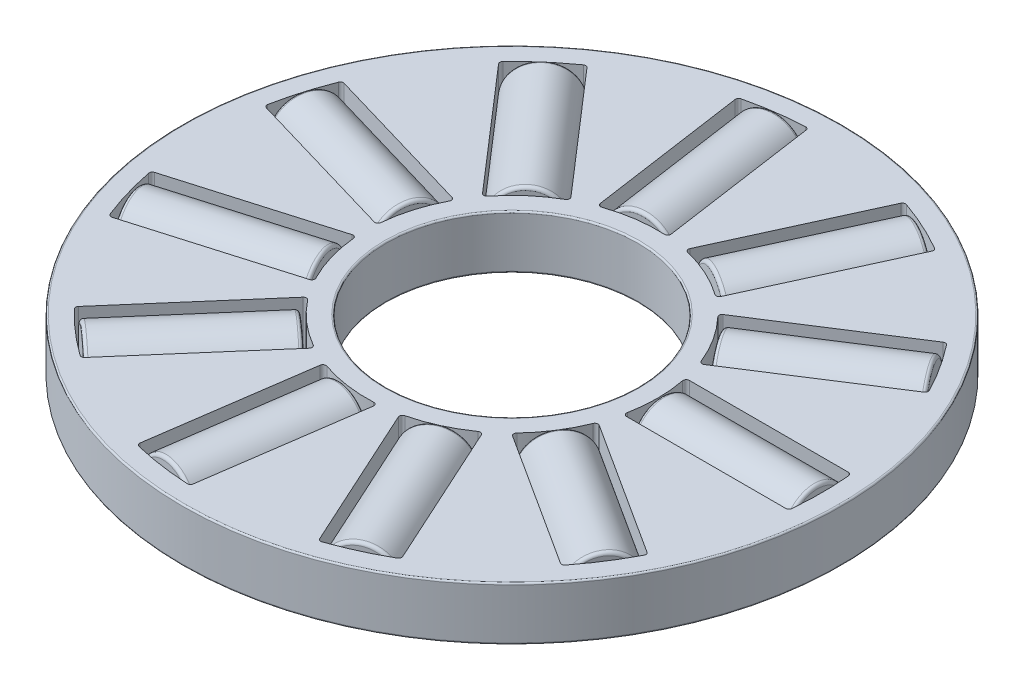
from build123d import *

# Parameters (mm, degrees)
SKETCH3_W                = 6.4875
SKETCH3_H                = 1.7
FILLET1_R                = 0.05
CUT_EXTRUDE1_DEPTH       = 1.85
FILLET5_R                = 0.1
CIRPATTERN1_COUNT        = 11
FILLET5_OF_CIRPATTERN1_R = 0.1
SKETCH5_W                = 4.96375
SKETCH5_H                = 0.998287418
FILLET6_R                = 0.1
CIRPATTERN2_COUNT        = 11


with BuildPart() as part:
    # Sketch3 → Revolve1 (revolve)
    with BuildSketch(Plane(origin=(0, 0, 0), x_dir=(0, 0, -1), z_dir=(1, 0, 0))):
        with Locations((7.25625, 0)):
            Rectangle(SKETCH3_W, SKETCH3_H)
    revolve(axis=Axis((0, 1, 0), (0, -1, 0)))

    # Fillet1
    fillet1_edges = [part.edges().sort_by_distance(p)[0] for p in [
        (0, 0.85, 4.0125),
        (0, 0.85, 10.5),
        (0, -0.85, 10.5),
        (0, -0.85, 4.0125),
    ]]
    fillet(fillet1_edges, radius=FILLET1_R)

    # Sketch4 → Cut-Extrude1 (cut, symmetric)
    with BuildSketch(Plane(origin=(0, 0, 0), x_dir=(1, 0, 0), z_dir=(0, 1, 0))):
        with BuildLine():
            Line((4.528777813, 0.998287418), (9.811846334, 0.998287418))
            ThreePointArc((9.811846334, 0.998287418), (9.8625, 0), (9.811846334, -0.998287418))
            Line((9.811846334, -0.998287418), (4.528777813, -0.998287418))
            ThreePointArc((4.528777813, -0.998287418), (4.6375, 0), (4.528777813, 0.998287418))
        make_face()
    cut_extrude1 = extrude(amount=CUT_EXTRUDE1_DEPTH, both=True, mode=Mode.SUBTRACT)

    # Fillet5
    fillet5_edges = [part.edges().sort_by_distance(p)[0] for p in [
        (4.528777813, 0, 0.998287418),
        (4.528777813, 0, -0.998287418),
        (9.811846334, 0, -0.998287418),
        (9.811846334, 0, 0.998287418),
    ]]
    fillet(fillet5_edges, radius=FILLET5_R)

    # CirPattern1: Cut-Extrude1 ×11 about axis
    cirpattern1_axis = Axis((0, 0, 0), (0, 1, 0))
    for i in range(1, CIRPATTERN1_COUNT):
        add(cut_extrude1.rotate(cirpattern1_axis, i * 360 / CIRPATTERN1_COUNT), mode=Mode.SUBTRACT)

    # Fillet5 of CirPattern1
    fillet5_of_cirpattern1_edges = [part.edges().sort_by_distance(p)[0] for p in [
        (4.34956526, 0, -1.608629322),
        (3.270135409, 0, -3.288254956),
        (7.714535467, 0, -6.14449744),
        (8.793965318, 0, -4.464871806),
        (2.78939647, 0, -3.704817618),
        (0.973248119, 0, -4.534224779),
        (3.167914097, 0, -9.339872939),
        (4.984062448, 0, -8.510465778),
        (0.343614009, 0, -4.624752497),
        (-1.632638573, 0, -4.340610273),
        (-2.384497615, 0, -9.569904773),
        (-0.408245033, 0, -9.854046998),
        (-2.211263472, 0, -4.076361136),
        (-3.720174054, 0, -2.768882674),
        (-7.179848183, 0, -6.76155946),
        (-5.670937601, 0, -8.069037922),
        (-4.064080424, 0, -2.233753916),
        (-4.626580558, 0, -0.31805439),
        (-9.695647682, 0, -1.806466792),
        (-9.133147549, 0, -3.722166318),
        (-4.626580558, 0, 0.31805439),
        (-4.064080424, 0, 2.233753916),
        (-9.133147549, 0, 3.722166318),
        (-9.695647682, 0, 1.806466792),
        (-3.720174054, 0, 2.768882674),
        (-2.211263472, 0, 4.076361136),
        (-5.670937601, 0, 8.069037922),
        (-7.179848183, 0, 6.76155946),
        (-1.632638573, 0, 4.340610273),
        (0.343614009, 0, 4.624752497),
        (-0.408245033, 0, 9.854046998),
        (-2.384497615, 0, 9.569904773),
        (0.973248119, 0, 4.534224779),
        (2.78939647, 0, 3.704817618),
        (4.984062448, 0, 8.510465778),
        (3.167914097, 0, 9.339872939),
        (3.270135409, 0, 3.288254956),
        (4.34956526, 0, 1.608629322),
        (8.793965318, 0, 4.464871806),
        (7.714535467, 0, 6.14449744),
    ]]
    fillet(fillet5_of_cirpattern1_edges, radius=FILLET5_OF_CIRPATTERN1_R)


with BuildPart() as body_2:
    # Sketch5 → Revolve2 (revolve)
    with BuildSketch(Plane(origin=(0, 0, 0), x_dir=(1, 0, 0), z_dir=(0, 1, 0))):
        with Locations((7.25, 0.499143709)):
            Rectangle(SKETCH5_W, SKETCH5_H)
    revolve(axis=Axis((9.8625, 0, 0), (-1, 0, 0)))

    # Fillet6
    fillet6_edges = [body_2.edges().sort_by_distance(p)[0] for p in [
        (9.731875, 0, 0.998287418),
        (4.768125, 0, 0.998287418),
    ]]
    fillet(fillet6_edges, radius=FILLET6_R)


with BuildPart() as cirpattern2_1:
    # CirPattern2: pattern copy
    add(body_2.part.rotate(Axis((0, 0, 0), (0, 1, 0)), 1 * 360 / CIRPATTERN2_COUNT))


with BuildPart() as cirpattern2_2:
    # CirPattern2: pattern copy
    add(body_2.part.rotate(Axis((0, 0, 0), (0, 1, 0)), 2 * 360 / CIRPATTERN2_COUNT))


with BuildPart() as cirpattern2_3:
    # CirPattern2: pattern copy
    add(body_2.part.rotate(Axis((0, 0, 0), (0, 1, 0)), 3 * 360 / CIRPATTERN2_COUNT))


with BuildPart() as cirpattern2_4:
    # CirPattern2: pattern copy
    add(body_2.part.rotate(Axis((0, 0, 0), (0, 1, 0)), 4 * 360 / CIRPATTERN2_COUNT))


with BuildPart() as cirpattern2_5:
    # CirPattern2: pattern copy
    add(body_2.part.rotate(Axis((0, 0, 0), (0, 1, 0)), 5 * 360 / CIRPATTERN2_COUNT))


with BuildPart() as cirpattern2_6:
    # CirPattern2: pattern copy
    add(body_2.part.rotate(Axis((0, 0, 0), (0, 1, 0)), 6 * 360 / CIRPATTERN2_COUNT))


with BuildPart() as cirpattern2_7:
    # CirPattern2: pattern copy
    add(body_2.part.rotate(Axis((0, 0, 0), (0, 1, 0)), 7 * 360 / CIRPATTERN2_COUNT))


with BuildPart() as cirpattern2_8:
    # CirPattern2: pattern copy
    add(body_2.part.rotate(Axis((0, 0, 0), (0, 1, 0)), 8 * 360 / CIRPATTERN2_COUNT))


with BuildPart() as cirpattern2_9:
    # CirPattern2: pattern copy
    add(body_2.part.rotate(Axis((0, 0, 0), (0, 1, 0)), 9 * 360 / CIRPATTERN2_COUNT))


with BuildPart() as cirpattern2_10:
    # CirPattern2: pattern copy
    add(body_2.part.rotate(Axis((0, 0, 0), (0, 1, 0)), 10 * 360 / CIRPATTERN2_COUNT))


solid = Compound([part.part, body_2.part, cirpattern2_1.part, cirpattern2_2.part, cirpattern2_3.part, cirpattern2_4.part, cirpattern2_5.part, cirpattern2_6.part, cirpattern2_7.part, cirpattern2_8.part, cirpattern2_9.part, cirpattern2_10.part])
